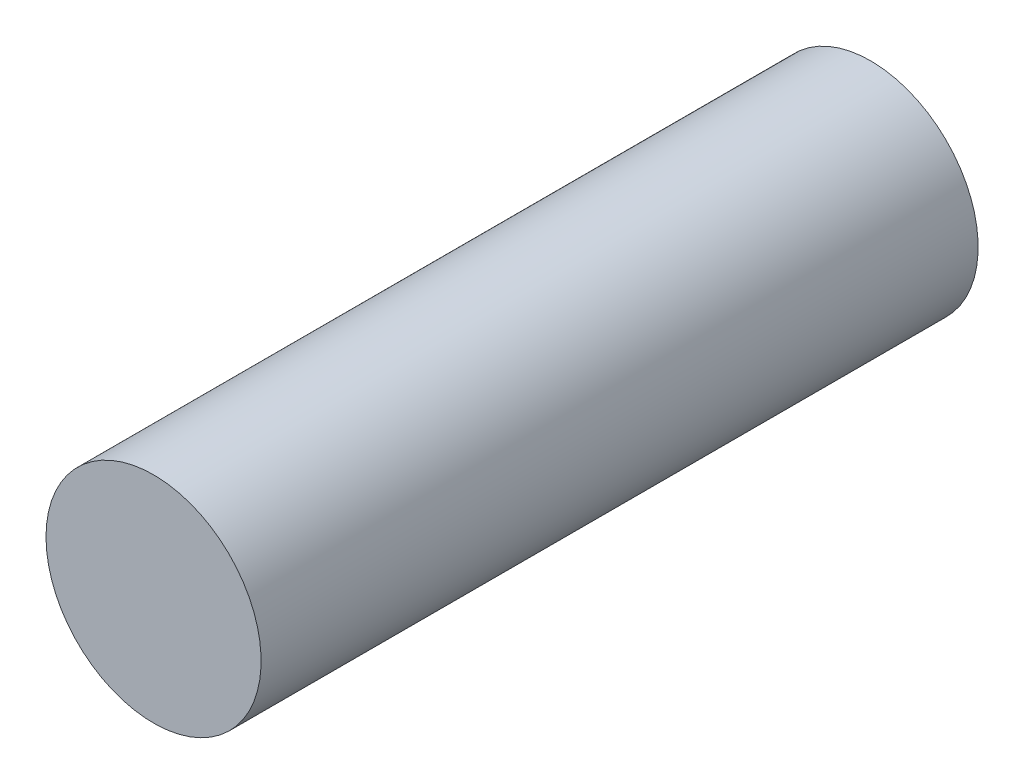
from build123d import *

# Parameters (mm, degrees)
SKETCH1_R           = 150
BOSS_EXTRUDE1_DEPTH = 1000


with BuildPart() as part:
    # Sketch1 → Boss-Extrude1 (new body)
    with BuildSketch(Plane(origin=(0, 0, -90.888438811), x_dir=(-1, 0, 0), z_dir=(0, 0, -1))):
        with Locations((-436.189955595, 444.523939136)):
            Circle(SKETCH1_R)
    extrude(amount=-BOSS_EXTRUDE1_DEPTH)


solid = part.part
